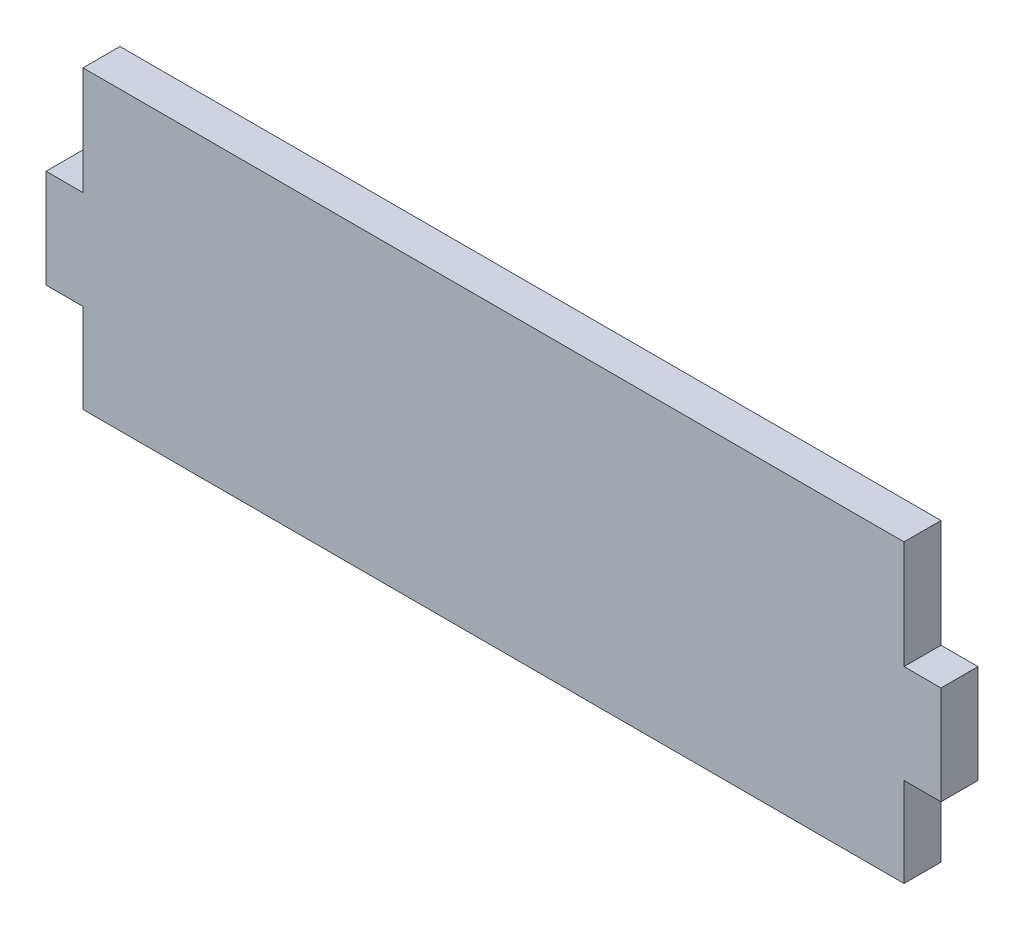
from build123d import *

# Parameters (mm, degrees)
CROQUIS1_W              = 111
CROQUIS1_H              = 40
SALIENTE_EXTRUIR1_DEPTH = 5
CROQUIS2_W              = 5
CROQUIS2_H              = 13.333333333
SALIENTE_EXTRUIR2_DEPTH = 5
CROQUIS3_W              = 5
CROQUIS3_H              = 13.333333333
SALIENTE_EXTRUIR3_DEPTH = 5


with BuildPart() as part:
    # Croquis1 → Saliente-Extruir1 (new body)
    with BuildSketch(Plane.XY):
        with Locations((55.5, 20)):
            Rectangle(CROQUIS1_W, CROQUIS1_H)
    extrude(amount=SALIENTE_EXTRUIR1_DEPTH)

    # Croquis2 → Saliente-Extruir2 (add)
    with BuildSketch(Plane(origin=(111, 0, 0), x_dir=(0, 0, -1), z_dir=(1, 0, 0))):
        with Locations((-2.5, 18.729999967)):
            Rectangle(CROQUIS2_W, CROQUIS2_H)
    extrude(amount=SALIENTE_EXTRUIR2_DEPTH)

    # Croquis3 → Saliente-Extruir3 (add)
    with BuildSketch(Plane.ZY):
        with Locations((2.5, 18.729999967)):
            Rectangle(CROQUIS3_W, CROQUIS3_H)
    extrude(amount=SALIENTE_EXTRUIR3_DEPTH)


solid = part.part
